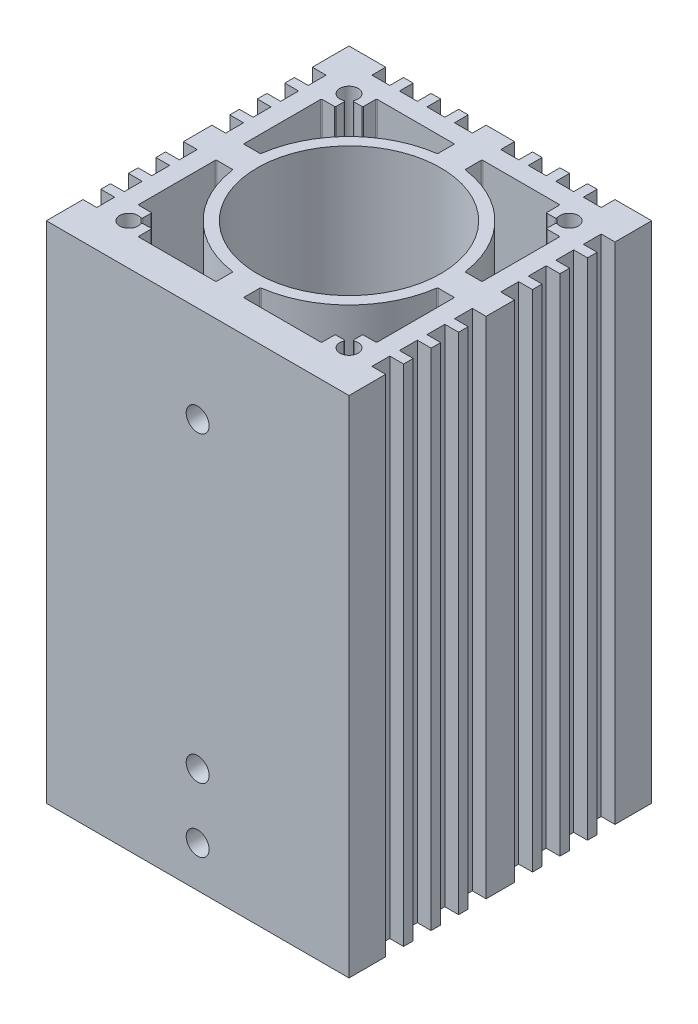
from build123d import *

# Parameters (mm, degrees)
CROQUIS1_R                                     = 10
SALIENTE_EXTRUIR1_DEPTH                        = 27.5
PERFORADOR_PARA_ROSCAR_PARA_MACHO_DE_ROS_REACH = 48.016
PERFORADOR_PARA_ROSCAR_PARA_MACHO_DE_2_R       = 1.25


with BuildPart() as part:
    # Croquis1 → Saliente-Extruir1 (new, symmetric)
    with BuildSketch(Plane(origin=(0, 0, 0), x_dir=(1, 0, 0), z_dir=(0, 1, 0))):
        Polygon((16.5, -1.55), (16.5, 1.55), (15, 1.55), (15, 3.5), (16.5, 3.5), (16.5, 4.55), (15, 4.55), (15, 6.5), (16.5, 6.5), (16.5, 7.55), (15, 7.55), (15, 9.5), (16.5, 9.5), (16.5, 10.55), (15, 10.55), (15, 12.5), (16.5, 12.5), (16.5, 16.5), (12.5, 16.5), (12.5, 15), (10.55, 15), (10.55, 16.5), (9.5, 16.5), (9.5, 15), (7.55, 15), (7.55, 16.5), (6.5, 16.5), (6.5, 15), (4.55, 15), (4.55, 16.5), (3.5, 16.5), (3.5, 15), (1.55, 15), (1.55, 16.5), (-1.55, 16.5), (-1.55, 15), (-3.5, 15), (-3.5, 16.5), (-4.55, 16.5), (-4.55, 15), (-6.5, 15), (-6.5, 16.5), (-7.55, 16.5), (-7.55, 15), (-9.5, 15), (-9.5, 16.5), (-10.55, 16.5), (-10.55, 15), (-12.5, 15), (-12.5, 16.5), (-16.5, 16.5), (-16.5, 12.5), (-15, 12.5), (-15, 10.55), (-16.5, 10.55), (-16.5, 9.5), (-15, 9.5), (-15, 7.55), (-16.5, 7.55), (-16.5, 6.5), (-15, 6.5), (-15, 4.55), (-16.5, 4.55), (-16.5, 3.5), (-15, 3.5), (-15, 1.55), (-16.5, 1.55), (-16.5, -1.55), (-15, -1.55), (-15, -3.5), (-16.5, -3.5), (-16.5, -4.55), (-15, -4.55), (-15, -6.5), (-16.5, -6.5), (-16.5, -7.55), (-15, -7.55), (-15, -9.5), (-16.5, -9.5), (-16.5, -10.55), (-15, -10.55), (-15, -12.5), (-16.5, -12.5), (-16.5, -16.5), (16.5, -16.5), (16.5, -12.5), (15, -12.5), (15, -10.55), (16.5, -10.55), (16.5, -9.5), (15, -9.5), (15, -7.55), (16.5, -7.55), (16.5, -6.5), (15, -6.5), (15, -4.55), (16.5, -4.55), (16.5, -3.5), (15, -3.5), (15, -1.55), align=None)
        with Locations(Location((0, 0, 0), (0, 0, 270))):
            Circle(CROQUIS1_R, mode=Mode.SUBTRACT)
        with BuildLine():
            Line((13, -9.9), (13, -1.6))
            ThreePointArc((13, -1.6), (12.970710678, -1.529289322), (12.9, -1.5))
            Line((12.9, -1.5), (11.236658756, -1.5))
            ThreePointArc((11.236658756, -1.5), (11.17112133, -1.52446957), (11.137657357, -1.585903084))
            ThreePointArc((11.137657357, -1.585903084), (7.954951288, -7.954951288), (1.585903084, -11.137657357))
            ThreePointArc((1.585903084, -11.137657357), (1.52446957, -11.17112133), (1.5, -11.236658756))
            Line((1.5, -11.236658756), (1.5, -12.9))
            ThreePointArc((1.5, -12.9), (1.529289322, -12.970710678), (1.6, -13))
            Line((1.6, -13), (9.9, -13))
            ThreePointArc((9.9, -13), (9.970710678, -12.970710678), (10, -12.9))
            Line((10, -12.9), (10, -11.6))
            ThreePointArc((10, -11.6), (10.029289322, -11.529289322), (10.1, -11.5))
            Line((10.1, -11.5), (10.975304923, -11.5))
            ThreePointArc((10.975304923, -11.5), (11.057877206, -11.543592393), (11.068459021, -11.636363636))
            ThreePointArc((11.068459021, -11.636363636), (12.707106781, -12.707106781), (11.636363636, -11.068459021))
            ThreePointArc((11.636363636, -11.068459021), (11.543592393, -11.057877206), (11.5, -10.975304923))
            Line((11.5, -10.975304923), (11.5, -10.1))
            ThreePointArc((11.5, -10.1), (11.529289322, -10.029289322), (11.6, -10))
            Line((11.6, -10), (12.9, -10))
            ThreePointArc((12.9, -10), (12.970710678, -9.970710678), (13, -9.9))
        make_face(mode=Mode.SUBTRACT)
        with BuildLine():
            Line((-9.9, -13), (-1.6, -13))
            ThreePointArc((-1.6, -13), (-1.529289322, -12.970710678), (-1.5, -12.9))
            Line((-1.5, -12.9), (-1.5, -11.236658756))
            ThreePointArc((-1.5, -11.236658756), (-1.52446957, -11.17112133), (-1.585903084, -11.137657357))
            ThreePointArc((-1.585903084, -11.137657357), (-7.954951288, -7.954951288), (-11.137657357, -1.585903084))
            ThreePointArc((-11.137657357, -1.585903084), (-11.17112133, -1.52446957), (-11.236658756, -1.5))
            Line((-11.236658756, -1.5), (-12.9, -1.5))
            ThreePointArc((-12.9, -1.5), (-12.970710678, -1.529289322), (-13, -1.6))
            Line((-13, -1.6), (-13, -9.9))
            ThreePointArc((-13, -9.9), (-12.970710678, -9.970710678), (-12.9, -10))
            Line((-12.9, -10), (-11.6, -10))
            ThreePointArc((-11.6, -10), (-11.529289322, -10.029289322), (-11.5, -10.1))
            Line((-11.5, -10.1), (-11.5, -10.975304923))
            ThreePointArc((-11.5, -10.975304923), (-11.543592393, -11.057877206), (-11.636363636, -11.068459021))
            ThreePointArc((-11.636363636, -11.068459021), (-12.707106781, -12.707106781), (-11.068459021, -11.636363636))
            ThreePointArc((-11.068459021, -11.636363636), (-11.057877206, -11.543592393), (-10.975304923, -11.5))
            Line((-10.975304923, -11.5), (-10.1, -11.5))
            ThreePointArc((-10.1, -11.5), (-10.029289322, -11.529289322), (-10, -11.6))
            Line((-10, -11.6), (-10, -12.9))
            ThreePointArc((-10, -12.9), (-9.970710678, -12.970710678), (-9.9, -13))
        make_face(mode=Mode.SUBTRACT)
        with BuildLine():
            Line((-13, 9.9), (-13, 1.6))
            ThreePointArc((-13, 1.6), (-12.970710678, 1.529289322), (-12.9, 1.5))
            Line((-12.9, 1.5), (-11.236658756, 1.5))
            ThreePointArc((-11.236658756, 1.5), (-11.17112133, 1.52446957), (-11.137657357, 1.585903084))
            ThreePointArc((-11.137657357, 1.585903084), (-7.954951288, 7.954951288), (-1.585903084, 11.137657357))
            ThreePointArc((-1.585903084, 11.137657357), (-1.52446957, 11.17112133), (-1.5, 11.236658756))
            Line((-1.5, 11.236658756), (-1.5, 12.9))
            ThreePointArc((-1.5, 12.9), (-1.529289322, 12.970710678), (-1.6, 13))
            Line((-1.6, 13), (-9.9, 13))
            ThreePointArc((-9.9, 13), (-9.970710678, 12.970710678), (-10, 12.9))
            Line((-10, 12.9), (-10, 11.6))
            ThreePointArc((-10, 11.6), (-10.029289322, 11.529289322), (-10.1, 11.5))
            Line((-10.1, 11.5), (-10.975304923, 11.5))
            ThreePointArc((-10.975304923, 11.5), (-11.057877206, 11.543592393), (-11.068459021, 11.636363636))
            ThreePointArc((-11.068459021, 11.636363636), (-12.707106781, 12.707106781), (-11.636363636, 11.068459021))
            ThreePointArc((-11.636363636, 11.068459021), (-11.543592393, 11.057877206), (-11.5, 10.975304923))
            Line((-11.5, 10.975304923), (-11.5, 10.1))
            ThreePointArc((-11.5, 10.1), (-11.529289322, 10.029289322), (-11.6, 10))
            Line((-11.6, 10), (-12.9, 10))
            ThreePointArc((-12.9, 10), (-12.970710678, 9.970710678), (-13, 9.9))
        make_face(mode=Mode.SUBTRACT)
        with BuildLine():
            Line((9.9, 13), (1.6, 13))
            ThreePointArc((1.6, 13), (1.529289322, 12.970710678), (1.5, 12.9))
            Line((1.5, 12.9), (1.5, 11.236658756))
            ThreePointArc((1.5, 11.236658756), (1.52446957, 11.17112133), (1.585903084, 11.137657357))
            ThreePointArc((1.585903084, 11.137657357), (7.954951288, 7.954951288), (11.137657357, 1.585903084))
            ThreePointArc((11.137657357, 1.585903084), (11.17112133, 1.52446957), (11.236658756, 1.5))
            Line((11.236658756, 1.5), (12.9, 1.5))
            ThreePointArc((12.9, 1.5), (12.970710678, 1.529289322), (13, 1.6))
            Line((13, 1.6), (13, 9.9))
            ThreePointArc((13, 9.9), (12.970710678, 9.970710678), (12.9, 10))
            Line((12.9, 10), (11.6, 10))
            ThreePointArc((11.6, 10), (11.529289322, 10.029289322), (11.5, 10.1))
            Line((11.5, 10.1), (11.5, 10.975304923))
            ThreePointArc((11.5, 10.975304923), (11.543592393, 11.057877206), (11.636363636, 11.068459021))
            ThreePointArc((11.636363636, 11.068459021), (12.707106781, 12.707106781), (11.068459021, 11.636363636))
            ThreePointArc((11.068459021, 11.636363636), (11.057877206, 11.543592393), (10.975304923, 11.5))
            Line((10.975304923, 11.5), (10.1, 11.5))
            ThreePointArc((10.1, 11.5), (10.029289322, 11.529289322), (10, 11.6))
            Line((10, 11.6), (10, 12.9))
            ThreePointArc((10, 12.9), (9.970710678, 12.970710678), (9.9, 13))
        make_face(mode=Mode.SUBTRACT)
    extrude(amount=SALIENTE_EXTRUIR1_DEPTH, both=True)

    # Perforador para roscar para macho de 2 → Perforador para roscar para macho de roscar para M31 (cut, up to next)
    with BuildSketch(Plane.XY.offset(16.5), mode=Mode.PRIVATE) as perforador_para_roscar_para_macho_de_ros_sk1:
        with Locations((0, 17)):
            Circle(PERFORADOR_PARA_ROSCAR_PARA_MACHO_DE_2_R)
    perforador_para_roscar_para_macho_de_ros_tool1 = extrude(perforador_para_roscar_para_macho_de_ros_sk1.sketch, amount=-PERFORADOR_PARA_ROSCAR_PARA_MACHO_DE_ROS_REACH, mode=Mode.PRIVATE) & part.part
    # Perforador para roscar para macho de 2 → Perforador para roscar para macho de roscar para M31 (cut, up to next)
    with BuildSketch(Plane.XY.offset(16.5), mode=Mode.PRIVATE) as perforador_para_roscar_para_macho_de_ros_sk2:
        with Locations((0, -16)):
            Circle(PERFORADOR_PARA_ROSCAR_PARA_MACHO_DE_2_R)
    perforador_para_roscar_para_macho_de_ros_tool2 = extrude(perforador_para_roscar_para_macho_de_ros_sk2.sketch, amount=-PERFORADOR_PARA_ROSCAR_PARA_MACHO_DE_ROS_REACH, mode=Mode.PRIVATE) & part.part
    # Perforador para roscar para macho de 2 → Perforador para roscar para macho de roscar para M31 (cut, up to next)
    with BuildSketch(Plane.XY.offset(16.5), mode=Mode.PRIVATE) as perforador_para_roscar_para_macho_de_ros_sk3:
        with Locations((0, -23)):
            Circle(PERFORADOR_PARA_ROSCAR_PARA_MACHO_DE_2_R)
    perforador_para_roscar_para_macho_de_ros_tool3 = extrude(perforador_para_roscar_para_macho_de_ros_sk3.sketch, amount=-PERFORADOR_PARA_ROSCAR_PARA_MACHO_DE_ROS_REACH, mode=Mode.PRIVATE) & part.part
    add(perforador_para_roscar_para_macho_de_ros_tool1.solids().sort_by_distance((0, 17, 16.5))[0], mode=Mode.SUBTRACT)
    add(perforador_para_roscar_para_macho_de_ros_tool2.solids().sort_by_distance((0, -16, 16.5))[0], mode=Mode.SUBTRACT)
    add(perforador_para_roscar_para_macho_de_ros_tool3.solids().sort_by_distance((0, -23, 16.5))[0], mode=Mode.SUBTRACT)


solid = part.part
